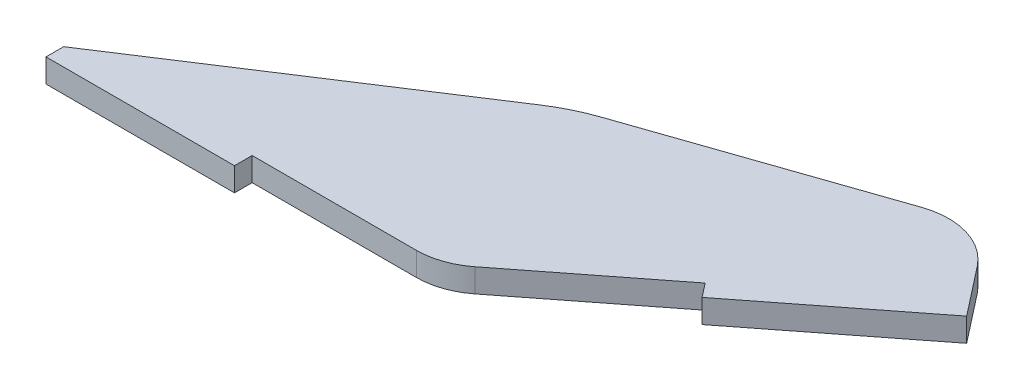
from build123d import *

# Parameters (mm, degrees)
BOSS_EXTRUDE1_DEPTH = 3.175
SKETCH2_W           = 25.4
SKETCH2_H           = 2.38125
BOSS_EXTRUDE2_DEPTH = 3.175
FILLET1_R           = 9.525
CUT_EXTRUDE1_DEPTH  = 4.175
FILLET2_R           = 25.4


with BuildPart() as part:
    # Sketch1 → Boss-Extrude1 (new body)
    with BuildSketch(Plane(origin=(0, 0, 0), x_dir=(1, 0, 0), z_dir=(0, 1, 0))):
        Polygon((-50.8, 0), (0, 0), (40.030946283, 31.275602947), (32.212045547, 41.283339517), (-50.8, 12.7), align=None)
    extrude(amount=BOSS_EXTRUDE1_DEPTH)

    # Sketch2 → Boss-Extrude2 (add)
    with BuildSketch(Plane(origin=(0, 3.175, 0), x_dir=(1, 0, 0), z_dir=(0, 1, 0))):
        Polygon((20.015473142, 15.637801473), (40.030946283, 31.275602947), (41.496990171, 29.39915234), (21.48151703, 13.761350866), align=None)
        with Locations((-38.1, -1.190625)):
            Rectangle(SKETCH2_W, SKETCH2_H)
    extrude(amount=-BOSS_EXTRUDE2_DEPTH)

    # Fillet1
    fillet1_edges = [part.edges().sort_by_distance(p)[0] for p in [
        (-50.8, 1.5875, -12.7),
        (32.212045547, 1.5875, -41.283339517),
        (0, 1.5875, 0),
    ]]
    fillet(fillet1_edges, radius=FILLET1_R)

    # Sketch3 → Cut-Extrude1 (cut, through all)
    with BuildSketch(Plane(origin=(0, 3.175, 0), x_dir=(1, 0, 0), z_dir=(0, 1, 0))):
        with BuildLine():
            Line((-50.8, 0), (-9.293977227, 26.991669759))
            Line((-9.293977227, 26.991669759), (-44.376036671, 14.911947961))
            ThreePointArc((-44.376036671, 14.911947961), (-49.029450312, 11.437079181), (-50.8, 5.905883528))
            Line((-50.8, 5.905883528), (-50.8, 0))
        make_face()
    extrude(amount=-CUT_EXTRUDE1_DEPTH, mode=Mode.SUBTRACT)

    # Fillet2
    fillet2_edges = [part.edges().sort_by_distance(p)[0] for p in [
        (-9.293977227, 1.5875, -26.991669759),
    ]]
    fillet(fillet2_edges, radius=FILLET2_R)


solid = part.part
